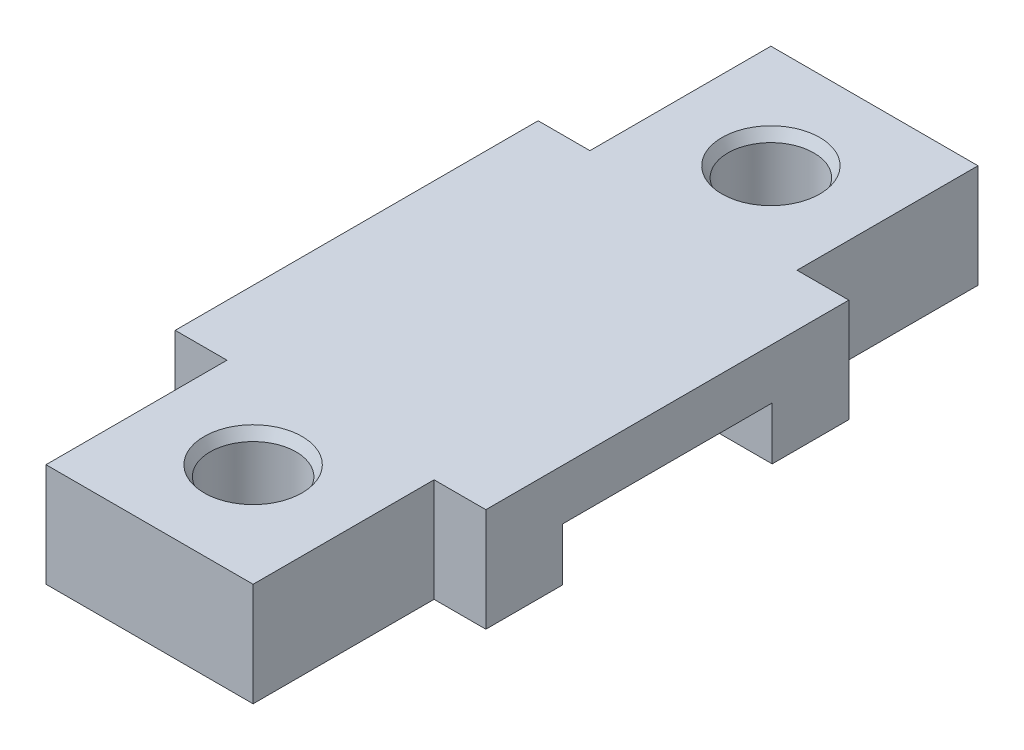
from build123d import *

# Parameters (mm, degrees)
SKETCH1_W                = 20
SKETCH1_H                = 70
BOSS_EXTRUDE1_DEPTH      = 10
SKETCH2_W                = 20.25
SKETCH2_H                = 5.1
CUT_EXTRUDE1_DEPTH       = 1
CUT_EXTRUDE1_DEPTH_BACK  = 21
SKETCH3_R                = 4.15
CUT_EXTRUDE2_DEPTH       = 11
BOSS_EXTRUDE2_DEPTH      = 5
BOSS_EXTRUDE2_DEPTH_BACK = 25
CHAMFER1_SIZE            = 1
CHAMFER1_SIZE2           = 0.577350269
CHAMFER1_PART_2_SIZE     = 1
CHAMFER1_PART_2_SIZE2    = 0.577350269


with BuildPart() as part:
    # Sketch1 → Boss-Extrude1 (new body)
    with BuildSketch(Plane(origin=(0, 0, 0), x_dir=(1, 0, 0), z_dir=(0, 1, 0))):
        Rectangle(SKETCH1_W, SKETCH1_H)
    extrude(amount=BOSS_EXTRUDE1_DEPTH)

    # Sketch2 → Cut-Extrude1 (cut, two sides)
    with BuildSketch(Plane(origin=(10, 0, 0), x_dir=(0, 0, -1), z_dir=(1, 0, 0))) as cut_extrude1_sk:
        with Locations((0, 2.55)):
            Rectangle(SKETCH2_W, SKETCH2_H)
    extrude(amount=CUT_EXTRUDE1_DEPTH, mode=Mode.SUBTRACT)
    extrude(cut_extrude1_sk.sketch, amount=-CUT_EXTRUDE1_DEPTH_BACK, mode=Mode.SUBTRACT)

    # Sketch3 → Cut-Extrude2 (cut, through all)
    with BuildSketch(Plane.XZ):
        with Locations((0, 25)):
            Circle(SKETCH3_R)
        with Locations((0, -25)):
            Circle(SKETCH3_R)
    extrude(amount=-CUT_EXTRUDE2_DEPTH, mode=Mode.SUBTRACT)

    # Sketch4 → Boss-Extrude2 (add, two sides)
    with BuildSketch(Plane(origin=(10, 0, 0), x_dir=(0, 0, -1), z_dir=(1, 0, 0))) as boss_extrude2_sk:
        Polygon((-10.125, 0), (-17.525, 0), (-17.525, 10), (17.525, 10), (17.525, 0), (10.125, 0), (10.125, 5.1), (-10.125, 5.1), align=None)
    extrude(amount=BOSS_EXTRUDE2_DEPTH)
    extrude(boss_extrude2_sk.sketch, amount=-BOSS_EXTRUDE2_DEPTH_BACK)

    # Chamfer1
    chamfer1_edges = [part.edges().sort_by_distance(p)[0] for p in [
        (-4.15, 10, 25),
    ]]
    chamfer1_side = [part.faces().sort_by_distance(p)[0] for p in [
        (-4.15, 5, 25),
    ]]
    chamfer(chamfer1_edges, length=CHAMFER1_SIZE, length2=CHAMFER1_SIZE2, reference=chamfer1_side[0])

    # Chamfer1 part 2
    chamfer1_part_2_edges = [part.edges().sort_by_distance(p)[0] for p in [
        (-4.15, 10, -25),
    ]]
    chamfer1_part_2_side = [part.faces().sort_by_distance(p)[0] for p in [
        (-4.15, 5, -25),
    ]]
    chamfer(chamfer1_part_2_edges, length=CHAMFER1_PART_2_SIZE, length2=CHAMFER1_PART_2_SIZE2, reference=chamfer1_part_2_side[0])


solid = part.part
